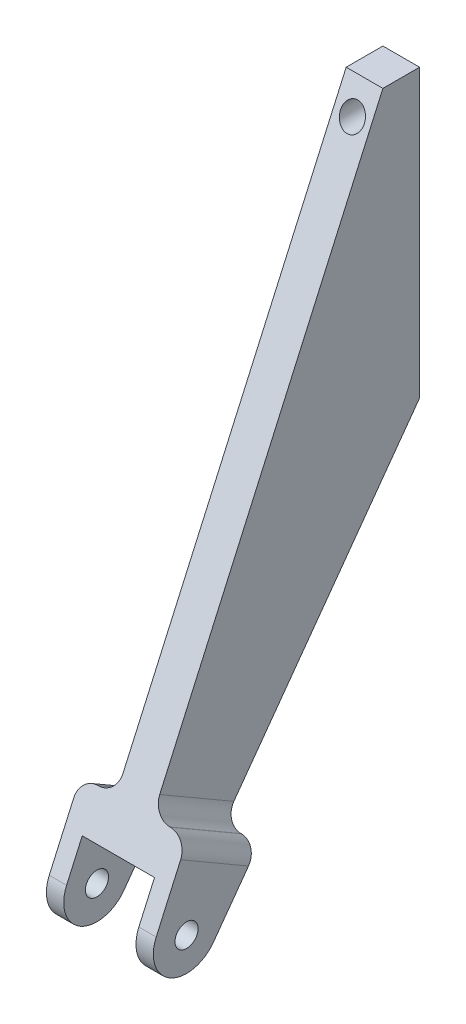
from build123d import *

# Parameters (mm, degrees)
SKETCH1_W           = 12.7
SKETCH1_H           = 319.323239592
BOSS_EXTRUDE1_DEPTH = 112.776
SKETCH2_R           = 4
CUT_EXTRUDE1_DEPTH  = 13.7
SKETCH3_R           = 4.1275
CUT_EXTRUDE2_DEPTH  = 25.4
SKETCH4_R           = 4
BOSS_EXTRUDE2_DEPTH = 18.5
CUT_EXTRUDE3_DEPTH  = 12.5
FILLET1_R           = 6
FILLET2_R           = 6


with BuildPart() as part:
    # Sketch1 → Boss-Extrude1 (new body)
    with BuildSketch(Plane.XY):
        with Locations((-72.058445247, -162.550776628)):
            Rectangle(SKETCH1_W, SKETCH1_H)
    extrude(amount=BOSS_EXTRUDE1_DEPTH)

    # Sketch2 → Cut-Extrude1 (cut, through all)
    with BuildSketch(Plane(origin=(-65.708445247, 0, 0), x_dir=(0, 0, -1), z_dir=(1, 0, 0))):
        with BuildLine():
            Line((0, -322.212396424), (0, -102))
            Line((0, -102), (-83.459642539, -217.229583096))
            ThreePointArc((-83.459642539, -217.229583096), (-98.52075591, -220.444553487), (-103.27456158, -205.796191727))
            Line((-103.27456158, -205.796191727), (-12.7, -2.889156832))
            Line((-12.7, -2.889156832), (-112.776, -2.889156832))
            Line((-112.776, -2.889156832), (-112.776, -322.212396424))
            Line((-112.776, -322.212396424), (0, -322.212396424))
        make_face()
        with Locations((-92.773303784, -210.483790762)):
            Circle(SKETCH2_R)
    extrude(amount=-CUT_EXTRUDE1_DEPTH, mode=Mode.SUBTRACT)

    # Sketch3 → Cut-Extrude2 (cut)
    with BuildSketch(Plane(origin=(0, 0, 0), x_dir=(-1, 0, 0), z_dir=(0, 0, -1))):
        with Locations((72, -12.414156832)):
            Circle(SKETCH3_R)
        with Locations((72, -91.789156832)):
            Circle(SKETCH3_R)
    extrude(amount=-CUT_EXTRUDE2_DEPTH, mode=Mode.SUBTRACT)

    # Sketch4 → Boss-Extrude2 (add, symmetric)
    with BuildSketch(Plane(origin=(-72.058445247, 0, 0), x_dir=(0, 0, -1), z_dir=(1, 0, 0))):
        with BuildLine():
            Line((-103.27456158, -205.796191727), (-92.366654545, -181.360069325))
            Line((-92.366654545, -181.360069325), (-67.7963289, -195.603836259))
            Line((-67.7963289, -195.603836259), (-83.459642539, -217.229583096))
            ThreePointArc((-83.459642539, -217.229583096), (-98.52075591, -220.444553487), (-103.27456158, -205.796191727))
        make_face()
        with Locations((-92.773303784, -210.483790762)):
            Circle(SKETCH4_R, mode=Mode.SUBTRACT)
    extrude(amount=BOSS_EXTRUDE2_DEPTH, both=True)

    # Sketch6 → Cut-Extrude3 (cut, symmetric)
    with BuildSketch(Plane(origin=(-72.058445247, 0, 0), x_dir=(0, 0, -1), z_dir=(1, 0, 0))):
        Polygon((-112.768060528, -185.021934277), (-58.643397137, -216.398770785), (-86.651018722, -272.391051709), (-155.398568229, -233.039813831), align=None)
    extrude(amount=CUT_EXTRUDE3_DEPTH, both=True, mode=Mode.SUBTRACT)

    # Fillet1
    fillet1_edges = [part.edges().sort_by_distance(p)[0] for p in [
        (-65.708445247, -188.481952792, 80.081491723),
        (-78.408445247, -188.481952792, 80.081491723),
    ]]
    fillet(fillet1_edges, radius=FILLET1_R)

    # Fillet2
    fillet2_edges = [part.edges().sort_by_distance(p)[0] for p in [
        (-90.558445247, -188.481952792, 80.081491723),
        (-53.558445247, -188.481952792, 80.081491723),
    ]]
    fillet(fillet2_edges, radius=FILLET2_R)


solid = part.part
